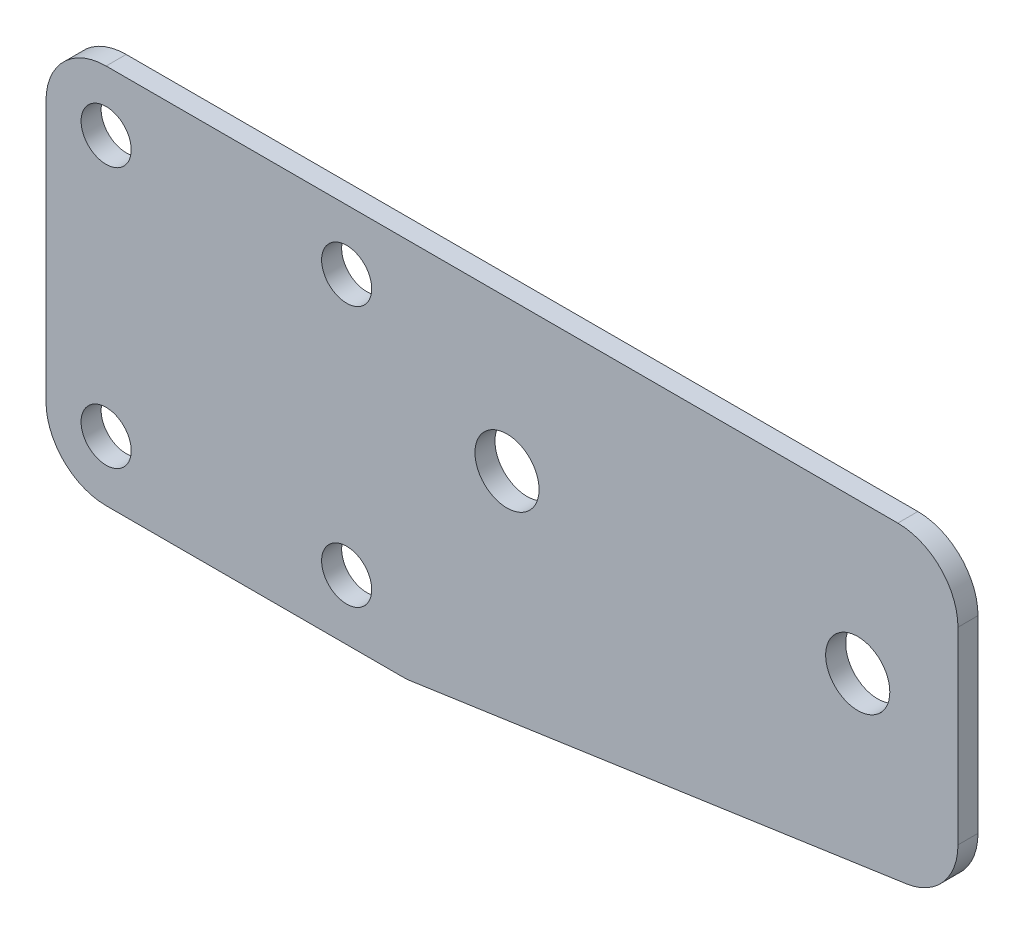
from build123d import *

# Parameters (mm, degrees)
ESBO_O1_R                = 1.25
ESBO_O1_R_2              = 1.6
RESSALTO_EXTRUS_O1_DEPTH = 1
FILETE1_R                = 3


with BuildPart() as part:
    # Esboço1 → Ressalto-extrusão1 (new body)
    with BuildSketch(Plane.XY):
        Polygon((-9, 9.5), (9, 9.5), (36.5, 9.5), (36.5, -5.5), (9, -9.5), (-9, -9.5), align=None)
        with Locations((6, -6.5)):
            Circle(ESBO_O1_R, mode=Mode.SUBTRACT)
        with Locations((6, 6.5)):
            Circle(ESBO_O1_R, mode=Mode.SUBTRACT)
        with Locations((-6, -6.5)):
            Circle(ESBO_O1_R, mode=Mode.SUBTRACT)
        with Locations((-6, 6.5)):
            Circle(ESBO_O1_R, mode=Mode.SUBTRACT)
        with Locations((31.5, 2)):
            Circle(ESBO_O1_R_2, mode=Mode.SUBTRACT)
        with Locations((14, 2)):
            Circle(ESBO_O1_R_2, mode=Mode.SUBTRACT)
    extrude(amount=RESSALTO_EXTRUS_O1_DEPTH)

    # Filete1
    filete1_edges = [part.edges().sort_by_distance(p)[0] for p in [
        (9, -9.5, 0.5),
        (-9, -9.5, 0.5),
        (-9, 9.5, 0.5),
        (36.5, 9.5, 0.5),
        (36.5, -5.5, 0.5),
    ]]
    fillet(filete1_edges, radius=FILETE1_R)


solid = part.part
